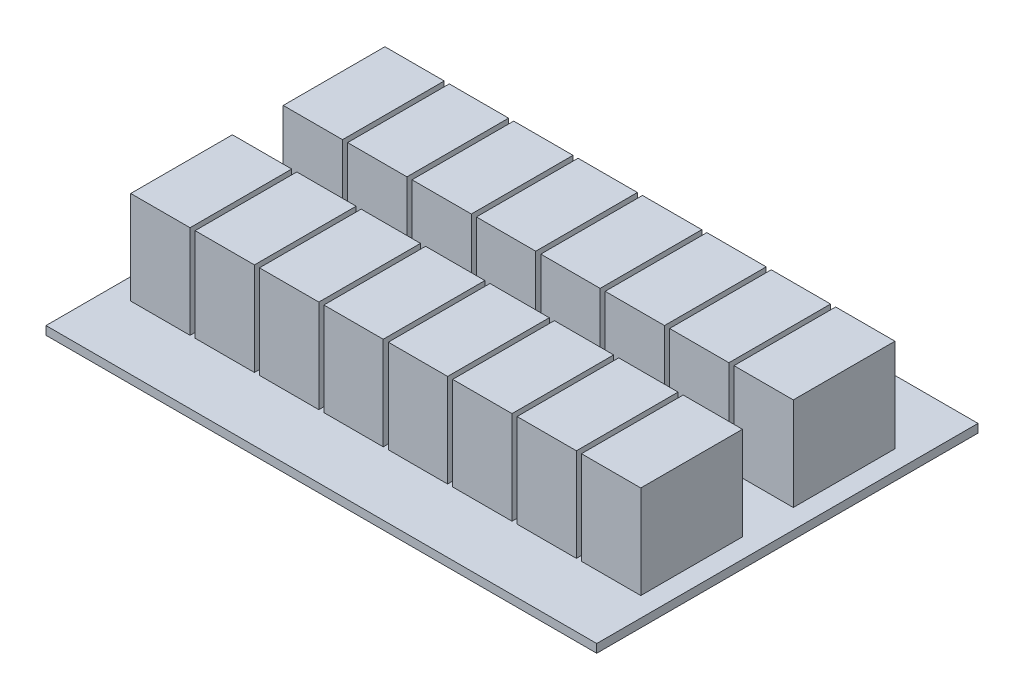
from build123d import *

# Parameters (mm, degrees)
SKETCH1_W           = 165.1
SKETCH1_H           = 114.3
BOSS_EXTRUDE1_DEPTH = 2.54
SKETCH2_W           = 17.78
SKETCH2_H           = 30.48
BOSS_EXTRUDE2_DEPTH = 27.94


with BuildPart() as part:
    # Sketch1 → Boss-Extrude1 (new body)
    with BuildSketch(Plane(origin=(0, 0, 0), x_dir=(1, 0, 0), z_dir=(0, 1, 0))):
        with Locations((16.813522013, 7.548113208)):
            Rectangle(SKETCH1_W, SKETCH1_H)
    extrude(amount=BOSS_EXTRUDE1_DEPTH)

    # Sketch2 → Boss-Extrude2 (add)
    with BuildSketch(Plane(origin=(0, 2.54, 0), x_dir=(1, 0, 0), z_dir=(0, 1, 0))):
        with Locations((65.327522013, 30.408113208)):
            Rectangle(SKETCH2_W, SKETCH2_H)
        with Locations((84.631522013, 30.408113208)):
            Rectangle(SKETCH2_W, SKETCH2_H)
        with Locations((46.023522013, 30.408113208)):
            Rectangle(SKETCH2_W, SKETCH2_H)
        with Locations((26.719522013, 30.408113208)):
            Rectangle(SKETCH2_W, SKETCH2_H)
        with Locations((7.415522013, 30.408113208)):
            Rectangle(SKETCH2_W, SKETCH2_H)
        with Locations((-11.888477987, 30.408113208)):
            Rectangle(SKETCH2_W, SKETCH2_H)
        with Locations((-31.192477987, 30.408113208)):
            Rectangle(SKETCH2_W, SKETCH2_H)
        with Locations((-50.496477987, 30.408113208)):
            Rectangle(SKETCH2_W, SKETCH2_H)
        with Locations((65.327522013, -15.311886792)):
            Rectangle(SKETCH2_W, SKETCH2_H)
        with Locations((46.023522013, -15.311886792)):
            Rectangle(SKETCH2_W, SKETCH2_H)
        with Locations((26.719522013, -15.311886792)):
            Rectangle(SKETCH2_W, SKETCH2_H)
        with Locations((7.415522013, -15.311886792)):
            Rectangle(SKETCH2_W, SKETCH2_H)
        with Locations((-11.888477987, -15.311886792)):
            Rectangle(SKETCH2_W, SKETCH2_H)
        with Locations((-31.192477987, -15.311886792)):
            Rectangle(SKETCH2_W, SKETCH2_H)
        with Locations((-50.496477987, -15.311886792)):
            Rectangle(SKETCH2_W, SKETCH2_H)
        with Locations((84.631522013, -15.311886792)):
            Rectangle(SKETCH2_W, SKETCH2_H)
    extrude(amount=BOSS_EXTRUDE2_DEPTH)


solid = part.part
